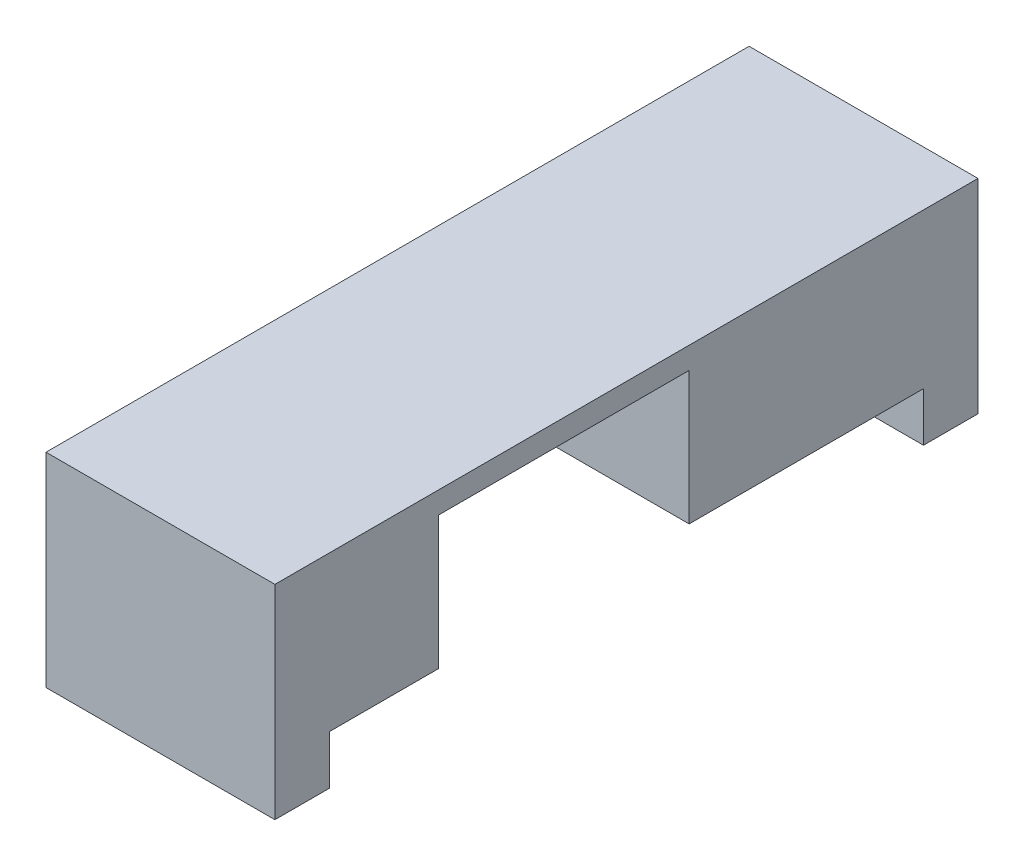
from build123d import *

# Parameters (mm, degrees)
SKETCH1_W           = 21
SKETCH1_H           = 64.5
BOSS_EXTRUDE1_DEPTH = 18.7
CUT_EXTRUDE1_DEPTH  = 22
SKETCH3_W           = 3.2
SKETCH3_H           = 4.5
CUT_EXTRUDE2_DEPTH  = 3


with BuildPart() as part:
    # Sketch1 → Boss-Extrude1 (new body)
    with BuildSketch(Plane(origin=(0, 0, 0), x_dir=(1, 0, 0), z_dir=(0, 1, 0))):
        with Locations((-10.5, -32.25)):
            Rectangle(SKETCH1_W, SKETCH1_H)
    extrude(amount=BOSS_EXTRUDE1_DEPTH)

    # Sketch2 → Cut-Extrude1 (cut, through all)
    with BuildSketch(Plane(origin=(0, 0, 0), x_dir=(0, 0, -1), z_dir=(1, 0, 0))):
        Polygon((-59.5, 0), (-5, 0), (-5, 4.5), (-26.5, 4.5), (-26.5, 16.7), (-49.5, 16.7), (-49.5, 4.5), (-59.5, 4.5), align=None)
    extrude(amount=-CUT_EXTRUDE1_DEPTH, mode=Mode.SUBTRACT)

    # Sketch3 → Cut-Extrude2 (cut)
    with BuildSketch(Plane(origin=(0, 0, 59.5), x_dir=(-1, 0, 0), z_dir=(0, 0, -1))):
        with Locations((13.9, 2.25)):
            Rectangle(SKETCH3_W, SKETCH3_H)
    extrude(amount=-CUT_EXTRUDE2_DEPTH, mode=Mode.SUBTRACT)


solid = part.part
